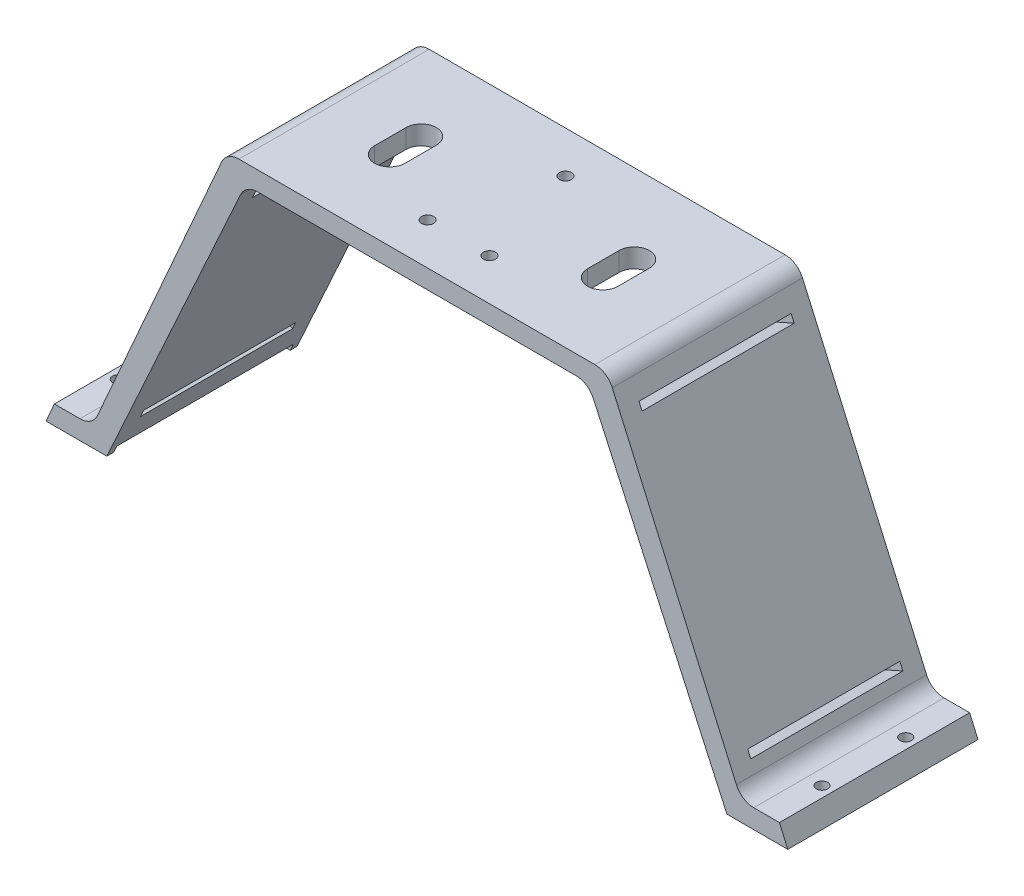
from build123d import *

# Parameters (mm, degrees)
BOSS_EXTRUDE2_DEPTH = 50
CUT_EXTRUDE1_DEPTH  = 50
FILLET1_R           = 5
SKETCH10_W          = 50
SKETCH10_H          = 5.46
BOSS_EXTRUDE4_DEPTH = 10
SKETCH5_W           = 50
SKETCH5_H           = 5.464
BOSS_EXTRUDE5_DEPTH = 10
SKETCH11_R          = 1.5
CUT_EXTRUDE2_DEPTH  = 10
SKETCH12_R          = 1.5
CUT_EXTRUDE3_DEPTH  = 10
FILLET2_R           = 5
FILLET3_R           = 5
CUT_EXTRUDE8_DEPTH  = 8.5
SKETCH18_W          = 15.2
SKETCH18_H          = 46.4
CUT_EXTRUDE14_DEPTH = 1.8
SKETCH19_W          = 15.2
SKETCH19_H          = 46.4
CUT_EXTRUDE15_DEPTH = 1.8
SKETCH16_W          = 40
SKETCH16_H          = 2
CUT_EXTRUDE16_DEPTH = 10
SKETCH17_W          = 40
SKETCH17_H          = 2
CUT_EXTRUDE17_DEPTH = 10
SKETCH13_R          = 1.6
CUT_EXTRUDE18_DEPTH = 10
SKETCH20_R          = 2.5
CUT_EXTRUDE19_DEPTH = 1.5


with BuildPart() as part:
    # Sketch1 → Boss-Extrude2 (new body)
    with BuildSketch(Plane.XY):
        Polygon((-87.5, 0), (87.5, 0), (50.05, 85), (-50.05, 85), align=None)
    extrude(amount=BOSS_EXTRUDE2_DEPTH)

    # Sketch3 → Cut-Extrude1 (cut)
    with BuildSketch(Plane.XY.offset(50)):
        Polygon((-81.5, 0), (81.5, 0), (45.05, 80), (-45.05, 80), align=None)
    extrude(amount=-CUT_EXTRUDE1_DEPTH, mode=Mode.SUBTRACT)

    # Fillet1
    fillet1_edges = [part.edges().sort_by_distance(p)[0] for p in [
        (-45.05, 80, 25),
        (45.05, 80, 25),
    ]]
    fillet(fillet1_edges, radius=FILLET1_R)

    # Sketch10 → Boss-Extrude4 (add, along a direction that is not the sketch's normal)
    with BuildSketch(Plane(origin=(-73.275840836, 32.284473404, 0), x_dir=(0, 0, 1), z_dir=(-0.915116485, 0.403189557, 0))):
        with Locations((25, -32.549086253)):
            Rectangle(SKETCH10_W, SKETCH10_H)
    extrude(amount=BOSS_EXTRUDE4_DEPTH, dir=(-1, 0, 0))

    # Sketch5 → Boss-Extrude5 (add, along a direction that is not the sketch's normal)
    with BuildSketch(Plane(origin=(73.275840836, 32.284473404, 0), x_dir=(0, 0, -1), z_dir=(0.915116485, 0.403189557, 0))):
        with Locations((-25, -32.547086253)):
            Rectangle(SKETCH5_W, SKETCH5_H)
    extrude(amount=BOSS_EXTRUDE5_DEPTH, dir=(1, 0, 0))

    # Sketch11 → Cut-Extrude2 (cut)
    with BuildSketch(Plane(origin=(0, 4.996536008, 0), x_dir=(1, 0, 0), z_dir=(0, 1, 0))):
        with Locations((-92.5, -14)):
            Circle(SKETCH11_R)
        with Locations((-92.5, -36)):
            Circle(SKETCH11_R)
    extrude(amount=-CUT_EXTRUDE2_DEPTH, mode=Mode.SUBTRACT)

    # Sketch12 → Cut-Extrude3 (cut)
    with BuildSketch(Plane(origin=(0, 5.000196474, 0), x_dir=(1, 0, 0), z_dir=(0, 1, 0))):
        with Locations((92.5, -14)):
            Circle(SKETCH12_R)
        with Locations((92.5, -36)):
            Circle(SKETCH12_R)
    extrude(amount=-CUT_EXTRUDE3_DEPTH, mode=Mode.SUBTRACT)

    # Fillet2
    fillet2_edges = [part.edges().sort_by_distance(p)[0] for p in [
        (-85.298585018, 4.996536008, 25),
        (85.29697226, 5.000196474, 25),
    ]]
    fillet(fillet2_edges, radius=FILLET2_R)

    # Fillet3
    fillet3_edges = [part.edges().sort_by_distance(p)[0] for p in [
        (-50.05, 85, 25),
        (50.05, 85, 25),
    ]]
    fillet(fillet3_edges, radius=FILLET3_R)

    # Sketch15 → Cut-Extrude8 (cut)
    with BuildSketch(Plane(origin=(0, 85, 0), x_dir=(1, 0, 0), z_dir=(0, 1, 0))):
        with BuildLine():
            Line((-23.999155874, -20.87), (-23.999155874, -29.13))
            ThreePointArc((-23.999155874, -29.13), (-27.999155874, -33.13), (-31.999155874, -29.13))
            Line((-31.999155874, -29.13), (-31.999155874, -20.87))
            ThreePointArc((-31.999155874, -20.87), (-27.999155874, -16.87), (-23.999155874, -20.87))
        make_face()
        with BuildLine():
            Line((32.000844126, -20.87), (32.000844126, -29.13))
            ThreePointArc((32.000844126, -29.13), (28.000844126, -33.13), (24.000844126, -29.13))
            Line((24.000844126, -29.13), (24.000844126, -20.87))
            ThreePointArc((24.000844126, -20.87), (28.000844126, -16.87), (32.000844126, -20.87))
        make_face()
    extrude(amount=-CUT_EXTRUDE8_DEPTH, mode=Mode.SUBTRACT)

    # Sketch18 → Cut-Extrude14 (cut)
    with BuildSketch(Plane.XZ):
        with Locations((88.1, 25)):
            Rectangle(SKETCH18_W, SKETCH18_H)
    extrude(amount=-CUT_EXTRUDE14_DEPTH, mode=Mode.SUBTRACT)

    # Sketch19 → Cut-Extrude15 (cut)
    with BuildSketch(Plane.XZ):
        with Locations((-88.1, 25)):
            Rectangle(SKETCH19_W, SKETCH19_H)
    extrude(amount=-CUT_EXTRUDE15_DEPTH, mode=Mode.SUBTRACT)

    # Sketch16 → Cut-Extrude16 (cut)
    with BuildSketch(Plane(origin=(73.275840836, 32.284473404, 0), x_dir=(0, 0, -1), z_dir=(0.915116485, 0.403189557, 0))):
        with Locations((-25, 48.344419756)):
            Rectangle(SKETCH16_W, SKETCH16_H)
        with Locations((-25, -22.554242128)):
            Rectangle(SKETCH16_W, SKETCH16_H)
    extrude(amount=-CUT_EXTRUDE16_DEPTH, mode=Mode.SUBTRACT)

    # Sketch17 → Cut-Extrude17 (cut)
    with BuildSketch(Plane(origin=(-73.275840836, 32.284473404, 0), x_dir=(0, 0, 1), z_dir=(-0.915116485, 0.403189557, 0))):
        with Locations((25, 48.344419756)):
            Rectangle(SKETCH17_W, SKETCH17_H)
        with Locations((25, -22.558242128)):
            Rectangle(SKETCH17_W, SKETCH17_H)
    extrude(amount=-CUT_EXTRUDE17_DEPTH, mode=Mode.SUBTRACT)

    # Sketch13 → Cut-Extrude18 (cut)
    with BuildSketch(Plane(origin=(0, 85, 0), x_dir=(1, 0, 0), z_dir=(0, 1, 0))):
        with Locations((0.000844126, -10.945)):
            Circle(SKETCH13_R)
        with Locations((-8.129155874, -39.055)):
            Circle(SKETCH13_R)
        with Locations((8.130844126, -39.055)):
            Circle(SKETCH13_R)
    extrude(amount=-CUT_EXTRUDE18_DEPTH, mode=Mode.SUBTRACT)

    # Sketch20 → Cut-Extrude19 (cut)
    with BuildSketch(Plane.XZ.offset(-80)):
        with Locations((-8.129155874, 39.055)):
            Circle(SKETCH20_R)
        with Locations((8.130844126, 39.055)):
            Circle(SKETCH20_R)
        with Locations((0.000844126, 10.945)):
            Circle(SKETCH20_R)
    extrude(amount=-CUT_EXTRUDE19_DEPTH, mode=Mode.SUBTRACT)


solid = part.part
